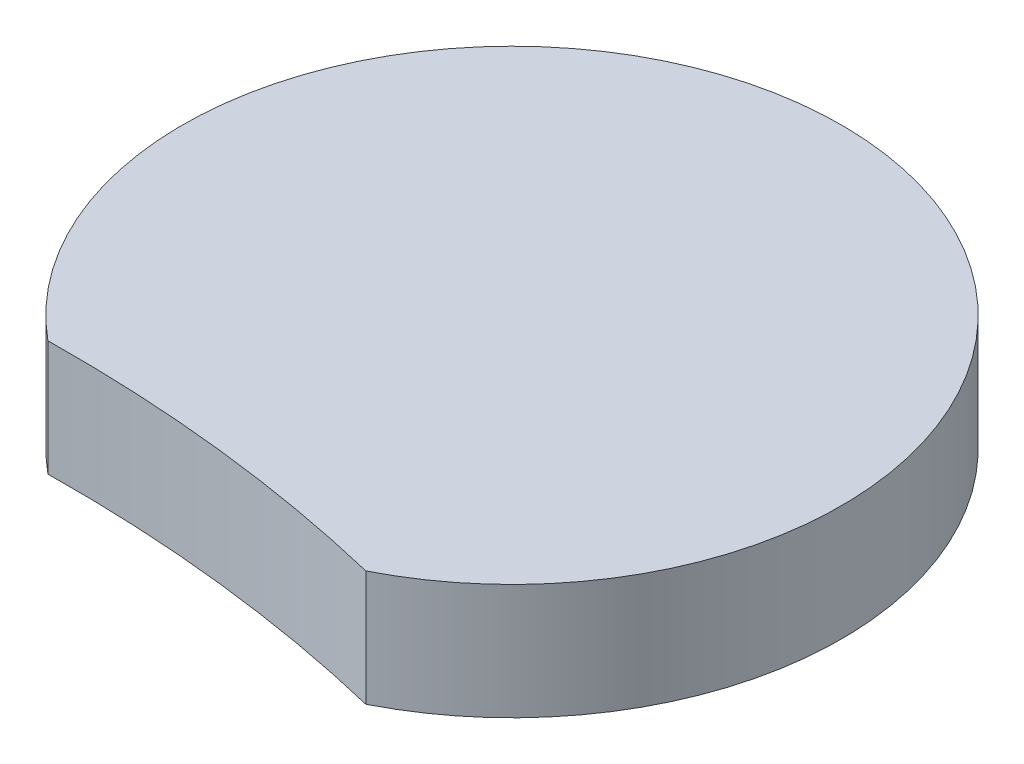
from build123d import *

# Parameters (mm, degrees)
SKETCH1_R           = 5.25
BOSS_EXTRUDE1_DEPTH = 2.5
BOSS_EXTRUDE2_DEPTH = 2.3


with BuildPart() as part:
    # Sketch1 → Boss-Extrude1 (new body)
    with BuildSketch(Plane(origin=(0, 0, 0), x_dir=(1, 0, 0), z_dir=(0, 1, 0))):
        with BuildLine():
            ThreePointArc((6.154078518, -12.360831122), (11.656426966, -7.310595529), (13.692219593, -0.124757626))
            ThreePointArc((13.692219593, -0.124757626), (-5.843155784, 12.270337945), (-8.736743065, -10.683886895))
            ThreePointArc((-8.736743065, -10.683886895), (-1.238774651, -11.05566121), (6.154078518, -12.360831122))
        make_face()
        with Locations((-0.007780407, -0.124757626)):
            Circle(SKETCH1_R, mode=Mode.SUBTRACT)
    extrude(amount=BOSS_EXTRUDE1_DEPTH)

    # Sketch2 → Boss-Extrude2 (add)
    with BuildSketch(Plane(origin=(0, 2.5, 0), x_dir=(1, 0, 0), z_dir=(0, 1, 0))):
        with BuildLine():
            ThreePointArc((6.154078518, -12.360831122), (-1.238774651, -11.05566121), (-8.736743065, -10.683886895))
            ThreePointArc((-8.736743065, -10.683886895), (1.52536697, 13.489185929), (6.154078518, -12.360831122))
        make_face()
    extrude(amount=BOSS_EXTRUDE2_DEPTH)


solid = part.part
